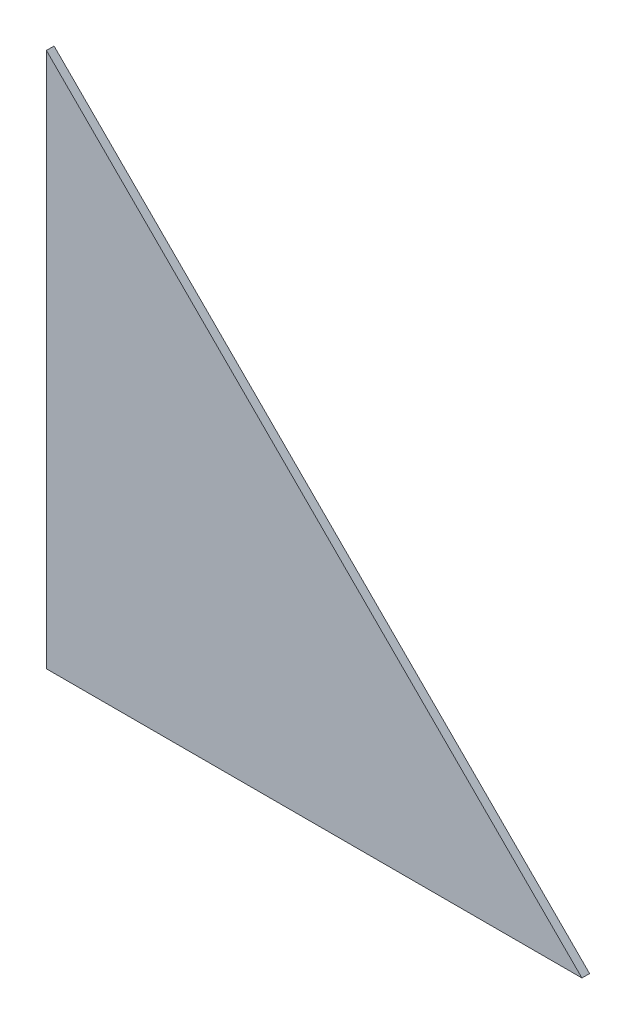
from build123d import *

# Parameters (mm, degrees)
EXTRUDE_1_DEPTH = 1


with BuildPart() as part:
    # 草图1 → 凸台-拉伸1 (new body)
    with BuildSketch(Plane.XY):
        Polygon((0, 70), (70, 0), (0, 0), align=None)
    extrude(amount=EXTRUDE_1_DEPTH)


solid = part.part
